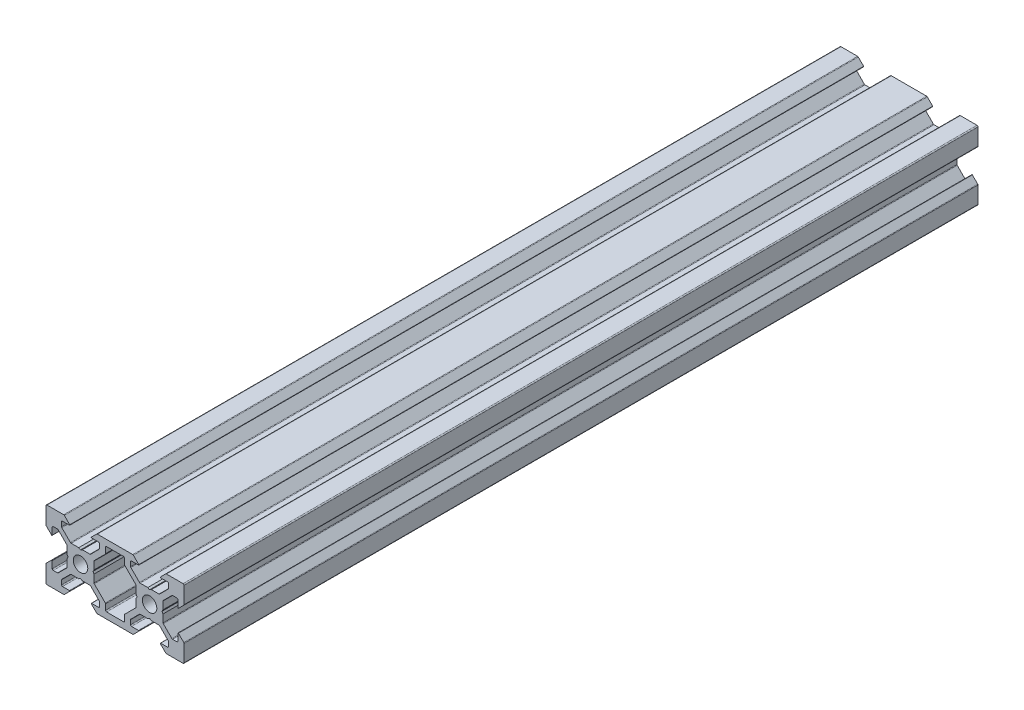
from build123d import *

# Parameters (mm, degrees)
BOSS_EXTRU_2_DEPTH = 230


with BuildPart() as part:
    # Esquisse1 → Boss.-Extru.2 (new body)
    with BuildSketch(Plane.XY):
        with BuildLine():
            Line((12.187742376, 2.734678815), (11.668127134, 3.034678815))
            Line((11.668127134, 3.034678815), (9.472006445, 3.034678815))
            ThreePointArc((9.472006445, 3.034678815), (9.357201415, 3.057514955), (9.25987441, 3.12254678))
            Line((9.25987441, 3.12254678), (6.776270514, 5.606150677))
            ThreePointArc((6.776270514, 5.606150677), (6.711238688, 5.703477682), (6.688402548, 5.818282711))
            Line((6.688402548, 5.818282711), (6.688402548, 7.034018643))
            ThreePointArc((6.688402548, 7.034018643), (6.776270514, 7.246150677), (6.988402548, 7.334018643))
            Line((6.988402548, 7.334018643), (8.987742376, 7.334018643))
            ThreePointArc((8.987742376, 7.334018643), (9.080130329, 7.3957503), (9.058453054, 7.504729321))
            Line((9.058453054, 7.504729321), (7.517031698, 9.046150677))
            ThreePointArc((7.517031698, 9.046150677), (7.419704693, 9.111182503), (7.304899664, 9.134018643))
            Line((7.304899664, 9.134018643), (2.187742376, 9.134018643))
            Line((2.187742376, 9.134018643), (-2.929414911, 9.134018643))
            ThreePointArc((-2.929414911, 9.134018643), (-3.044219941, 9.111182503), (-3.141546946, 9.046150677))
            Line((-3.141546946, 9.046150677), (-4.682968302, 7.504729321))
            ThreePointArc((-4.682968302, 7.504729321), (-4.704645577, 7.3957503), (-4.612257624, 7.334018643))
            Line((-4.612257624, 7.334018643), (-2.612917796, 7.334018643))
            ThreePointArc((-2.612917796, 7.334018643), (-2.400785761, 7.246150677), (-2.312917796, 7.034018643))
            Line((-2.312917796, 7.034018643), (-2.312917796, 5.818282711))
            ThreePointArc((-2.312917796, 5.818282711), (-2.335753936, 5.703477682), (-2.400785761, 5.606150677))
            Line((-2.400785761, 5.606150677), (-4.884389658, 3.12254678))
            ThreePointArc((-4.884389658, 3.12254678), (-4.981716663, 3.057514955), (-5.096521693, 3.034678815))
            Line((-5.096521693, 3.034678815), (-7.292642382, 3.034678815))
            Line((-7.292642382, 3.034678815), (-7.812257624, 2.734678815))
            Line((-7.812257624, 2.734678815), (-8.331872866, 3.034678815))
            Line((-8.331872866, 3.034678815), (-10.527993555, 3.034678815))
            ThreePointArc((-10.527993555, 3.034678815), (-10.642798585, 3.057514955), (-10.74012559, 3.12254678))
            Line((-10.74012559, 3.12254678), (-13.223729486, 5.606150677))
            ThreePointArc((-13.223729486, 5.606150677), (-13.288761312, 5.703477682), (-13.311597452, 5.818282711))
            Line((-13.311597452, 5.818282711), (-13.311597452, 7.034018643))
            ThreePointArc((-13.311597452, 7.034018643), (-13.223729486, 7.246150677), (-13.011597452, 7.334018643))
            Line((-13.011597452, 7.334018643), (-11.012257624, 7.334018643))
            ThreePointArc((-11.012257624, 7.334018643), (-10.919869671, 7.3957503), (-10.941546946, 7.504729321))
            Line((-10.941546946, 7.504729321), (-12.482968302, 9.046150677))
            ThreePointArc((-12.482968302, 9.046150677), (-12.580295307, 9.111182503), (-12.695100336, 9.134018643))
            Line((-12.695100336, 9.134018643), (-17.512257624, 9.134018643))
            ThreePointArc((-17.512257624, 9.134018643), (-17.724389658, 9.046150677), (-17.812257624, 8.834018643))
            Line((-17.812257624, 8.834018643), (-17.812257624, 4.016861355))
            ThreePointArc((-17.812257624, 4.016861355), (-17.789421484, 3.902056326), (-17.724389658, 3.804729321))
            Line((-17.724389658, 3.804729321), (-16.182968302, 2.263307965))
            ThreePointArc((-16.182968302, 2.263307965), (-16.073989281, 2.24163069), (-16.012257624, 2.334018643))
            Line((-16.012257624, 2.334018643), (-16.012257624, 4.333358471))
            ThreePointArc((-16.012257624, 4.333358471), (-15.924389658, 4.545490505), (-15.712257624, 4.633358471))
            Line((-15.712257624, 4.633358471), (-14.496521693, 4.633358471))
            ThreePointArc((-14.496521693, 4.633358471), (-14.381716663, 4.610522331), (-14.284389658, 4.545490505))
            Line((-14.284389658, 4.545490505), (-11.800785761, 2.061886608))
            ThreePointArc((-11.800785761, 2.061886608), (-11.735753936, 1.964559604), (-11.712917796, 1.849754574))
            Line((-11.712917796, 1.849754574), (-11.712917796, -0.346366115))
            Line((-11.712917796, -0.346366115), (-11.412917796, -0.865981357))
            Line((-11.412917796, -0.865981357), (-11.712917796, -1.385596599))
            Line((-11.712917796, -1.385596599), (-11.712917796, -3.581717289))
            ThreePointArc((-11.712917796, -3.581717289), (-11.735753936, -3.696522318), (-11.800785761, -3.793849323))
            Line((-11.800785761, -3.793849323), (-14.284389658, -6.27745322))
            ThreePointArc((-14.284389658, -6.27745322), (-14.381716663, -6.342485045), (-14.496521693, -6.365321185))
            Line((-14.496521693, -6.365321185), (-15.712257624, -6.365321185))
            ThreePointArc((-15.712257624, -6.365321185), (-15.924389658, -6.27745322), (-16.012257624, -6.065321185))
            Line((-16.012257624, -6.065321185), (-16.012257624, -4.065981357))
            ThreePointArc((-16.012257624, -4.065981357), (-16.073989281, -3.973593404), (-16.182968302, -3.995270679))
            Line((-16.182968302, -3.995270679), (-17.724389658, -5.536692035))
            ThreePointArc((-17.724389658, -5.536692035), (-17.789421484, -5.63401904), (-17.812257624, -5.74882407))
            Line((-17.812257624, -5.74882407), (-17.812257624, -10.565981357))
            ThreePointArc((-17.812257624, -10.565981357), (-17.724389658, -10.778113392), (-17.512257624, -10.865981357))
            Line((-17.512257624, -10.865981357), (-12.695100336, -10.865981357))
            ThreePointArc((-12.695100336, -10.865981357), (-12.580295307, -10.843145217), (-12.482968302, -10.778113392))
            Line((-12.482968302, -10.778113392), (-10.941546946, -9.236692035))
            ThreePointArc((-10.941546946, -9.236692035), (-10.919869671, -9.127713014), (-11.012257624, -9.065981357))
            Line((-11.012257624, -9.065981357), (-13.011597452, -9.065981357))
            ThreePointArc((-13.011597452, -9.065981357), (-13.223729486, -8.978113392), (-13.311597452, -8.765981357))
            Line((-13.311597452, -8.765981357), (-13.311597452, -7.550245426))
            ThreePointArc((-13.311597452, -7.550245426), (-13.288761312, -7.435440396), (-13.223729486, -7.338113392))
            Line((-13.223729486, -7.338113392), (-10.74012559, -4.854509495))
            ThreePointArc((-10.74012559, -4.854509495), (-10.642798585, -4.789477669), (-10.527993555, -4.766641529))
            Line((-10.527993555, -4.766641529), (-8.331872866, -4.766641529))
            Line((-8.331872866, -4.766641529), (-7.812257624, -4.466641529))
            Line((-7.812257624, -4.466641529), (-7.292642382, -4.766641529))
            Line((-7.292642382, -4.766641529), (-5.096521693, -4.766641529))
            ThreePointArc((-5.096521693, -4.766641529), (-4.981716663, -4.789477669), (-4.884389658, -4.854509495))
            Line((-4.884389658, -4.854509495), (-2.400785761, -7.338113392))
            ThreePointArc((-2.400785761, -7.338113392), (-2.335753936, -7.435440396), (-2.312917796, -7.550245426))
            Line((-2.312917796, -7.550245426), (-2.312917796, -8.765981357))
            ThreePointArc((-2.312917796, -8.765981357), (-2.400785761, -8.978113392), (-2.612917796, -9.065981357))
            Line((-2.612917796, -9.065981357), (-4.612257624, -9.065981357))
            ThreePointArc((-4.612257624, -9.065981357), (-4.704645577, -9.127713014), (-4.682968302, -9.236692035))
            Line((-4.682968302, -9.236692035), (-3.141546946, -10.778113392))
            ThreePointArc((-3.141546946, -10.778113392), (-3.044219941, -10.843145217), (-2.929414911, -10.865981357))
            Line((-2.929414911, -10.865981357), (2.187742376, -10.865981357))
            Line((2.187742376, -10.865981357), (7.304899664, -10.865981357))
            ThreePointArc((7.304899664, -10.865981357), (7.419704693, -10.843145217), (7.517031698, -10.778113392))
            Line((7.517031698, -10.778113392), (9.058453054, -9.236692035))
            ThreePointArc((9.058453054, -9.236692035), (9.080130329, -9.127713014), (8.987742376, -9.065981357))
            Line((8.987742376, -9.065981357), (6.988402548, -9.065981357))
            ThreePointArc((6.988402548, -9.065981357), (6.776270514, -8.978113392), (6.688402548, -8.765981357))
            Line((6.688402548, -8.765981357), (6.688402548, -7.550245426))
            ThreePointArc((6.688402548, -7.550245426), (6.711238688, -7.435440396), (6.776270514, -7.338113392))
            Line((6.776270514, -7.338113392), (9.25987441, -4.854509495))
            ThreePointArc((9.25987441, -4.854509495), (9.357201415, -4.789477669), (9.472006445, -4.766641529))
            Line((9.472006445, -4.766641529), (11.668127134, -4.766641529))
            Line((11.668127134, -4.766641529), (12.187742376, -4.466641529))
            Line((12.187742376, -4.466641529), (12.707357618, -4.766641529))
            Line((12.707357618, -4.766641529), (14.903478307, -4.766641529))
            ThreePointArc((14.903478307, -4.766641529), (15.018283337, -4.789477669), (15.115610342, -4.854509495))
            Line((15.115610342, -4.854509495), (17.599214239, -7.338113392))
            ThreePointArc((17.599214239, -7.338113392), (17.664246064, -7.435440396), (17.687082204, -7.550245426))
            Line((17.687082204, -7.550245426), (17.687082204, -8.765981357))
            ThreePointArc((17.687082204, -8.765981357), (17.599214239, -8.978113392), (17.387082204, -9.065981357))
            Line((17.387082204, -9.065981357), (15.387742376, -9.065981357))
            ThreePointArc((15.387742376, -9.065981357), (15.295354423, -9.127713014), (15.317031698, -9.236692035))
            Line((15.317031698, -9.236692035), (16.858453054, -10.778113392))
            ThreePointArc((16.858453054, -10.778113392), (16.955780059, -10.843145217), (17.070585089, -10.865981357))
            Line((17.070585089, -10.865981357), (21.887742376, -10.865981357))
            ThreePointArc((21.887742376, -10.865981357), (22.099874411, -10.778113392), (22.187742376, -10.565981357))
            Line((22.187742376, -10.565981357), (22.187742376, -5.74882407))
            ThreePointArc((22.187742376, -5.74882407), (22.164906236, -5.63401904), (22.09987441, -5.536692035))
            Line((22.09987441, -5.536692035), (20.558453054, -3.995270679))
            ThreePointArc((20.558453054, -3.995270679), (20.449474033, -3.973593404), (20.387742376, -4.065981357))
            Line((20.387742376, -4.065981357), (20.387742376, -6.065321185))
            ThreePointArc((20.387742376, -6.065321185), (20.29987441, -6.27745322), (20.087742376, -6.365321185))
            Line((20.087742376, -6.365321185), (18.872006445, -6.365321185))
            ThreePointArc((18.872006445, -6.365321185), (18.757201415, -6.342485045), (18.65987441, -6.27745322))
            Line((18.65987441, -6.27745322), (16.176270514, -3.793849323))
            ThreePointArc((16.176270514, -3.793849323), (16.111238688, -3.696522318), (16.088402548, -3.581717289))
            Line((16.088402548, -3.581717289), (16.088402548, -1.385596599))
            Line((16.088402548, -1.385596599), (15.788402548, -0.865981357))
            Line((15.788402548, -0.865981357), (16.088402548, -0.346366115))
            Line((16.088402548, -0.346366115), (16.088402548, 1.849754574))
            ThreePointArc((16.088402548, 1.849754574), (16.111238688, 1.964559604), (16.176270514, 2.061886608))
            Line((16.176270514, 2.061886608), (18.659874411, 4.545490505))
            ThreePointArc((18.659874411, 4.545490505), (18.757201415, 4.610522331), (18.872006445, 4.633358471))
            Line((18.872006445, 4.633358471), (20.087742376, 4.633358471))
            ThreePointArc((20.087742376, 4.633358471), (20.299874411, 4.545490505), (20.387742376, 4.333358471))
            Line((20.387742376, 4.333358471), (20.387742376, 2.334018643))
            ThreePointArc((20.387742376, 2.334018643), (20.449474033, 2.24163069), (20.558453054, 2.263307965))
            Line((20.558453054, 2.263307965), (22.099874411, 3.804729321))
            ThreePointArc((22.099874411, 3.804729321), (22.164906236, 3.902056326), (22.187742376, 4.016861355))
            Line((22.187742376, 4.016861355), (22.187742376, 8.834018643))
            ThreePointArc((22.187742376, 8.834018643), (22.099874411, 9.046150677), (21.887742376, 9.134018643))
            Line((21.887742376, 9.134018643), (17.070585089, 9.134018643))
            ThreePointArc((17.070585089, 9.134018643), (16.955780059, 9.111182503), (16.858453054, 9.046150677))
            Line((16.858453054, 9.046150677), (15.317031698, 7.504729321))
            ThreePointArc((15.317031698, 7.504729321), (15.295354423, 7.3957503), (15.387742376, 7.334018643))
            Line((15.387742376, 7.334018643), (17.387082204, 7.334018643))
            ThreePointArc((17.387082204, 7.334018643), (17.599214239, 7.246150677), (17.687082204, 7.034018643))
            Line((17.687082204, 7.034018643), (17.687082204, 5.818282711))
            ThreePointArc((17.687082204, 5.818282711), (17.664246064, 5.703477682), (17.599214239, 5.606150677))
            Line((17.599214239, 5.606150677), (15.115610342, 3.12254678))
            ThreePointArc((15.115610342, 3.12254678), (15.018283337, 3.057514955), (14.903478307, 3.034678815))
            Line((14.903478307, 3.034678815), (12.707357618, 3.034678815))
            Line((12.707357618, 3.034678815), (12.187742376, 2.734678815))
        make_face()
        with BuildLine():
            Line((4.927082204, -8.765981357), (4.927082204, -7.190245426))
            ThreePointArc((4.927082204, -7.190245426), (4.949918345, -7.075440396), (5.01495017, -6.978113392))
            Line((5.01495017, -6.978113392), (8.199214239, -3.793849323))
            ThreePointArc((8.199214239, -3.793849323), (8.264246064, -3.696522318), (8.287082204, -3.581717289))
            Line((8.287082204, -3.581717289), (8.287082204, -1.385596599))
            Line((8.287082204, -1.385596599), (8.587082204, -0.865981357))
            Line((8.587082204, -0.865981357), (8.287082204, -0.346366115))
            Line((8.287082204, -0.346366115), (8.287082204, 1.849754574))
            ThreePointArc((8.287082204, 1.849754574), (8.264246064, 1.964559604), (8.199214239, 2.061886608))
            Line((8.199214239, 2.061886608), (5.01495017, 5.246150677))
            ThreePointArc((5.01495017, 5.246150677), (4.949918345, 5.343477682), (4.927082204, 5.458282711))
            Line((4.927082204, 5.458282711), (4.927082204, 7.034018643))
            ThreePointArc((4.927082204, 7.034018643), (4.839214239, 7.246150677), (4.627082204, 7.334018643))
            Line((4.627082204, 7.334018643), (2.187742376, 7.334018643))
            Line((2.187742376, 7.334018643), (-0.251597452, 7.334018643))
            ThreePointArc((-0.251597452, 7.334018643), (-0.463729486, 7.246150677), (-0.551597452, 7.034018643))
            Line((-0.551597452, 7.034018643), (-0.551597452, 5.458282711))
            ThreePointArc((-0.551597452, 5.458282711), (-0.574433592, 5.343477682), (-0.639465418, 5.246150677))
            Line((-0.639465418, 5.246150677), (-3.823729486, 2.061886608))
            ThreePointArc((-3.823729486, 2.061886608), (-3.888761312, 1.964559604), (-3.911597452, 1.849754574))
            Line((-3.911597452, 1.849754574), (-3.911597452, -0.346366115))
            Line((-3.911597452, -0.346366115), (-4.211597452, -0.865981357))
            Line((-4.211597452, -0.865981357), (-3.911597452, -1.385596599))
            Line((-3.911597452, -1.385596599), (-3.911597452, -3.581717289))
            ThreePointArc((-3.911597452, -3.581717289), (-3.888761312, -3.696522318), (-3.823729486, -3.793849323))
            Line((-3.823729486, -3.793849323), (-0.639465418, -6.978113392))
            ThreePointArc((-0.639465418, -6.978113392), (-0.574433592, -7.075440396), (-0.551597452, -7.190245426))
            Line((-0.551597452, -7.190245426), (-0.551597452, -8.765981357))
            ThreePointArc((-0.551597452, -8.765981357), (-0.463729486, -8.978113392), (-0.251597452, -9.065981357))
            Line((-0.251597452, -9.065981357), (2.187742376, -9.065981357))
            Line((2.187742376, -9.065981357), (4.627082204, -9.065981357))
            ThreePointArc((4.627082204, -9.065981357), (4.839214239, -8.978113392), (4.927082204, -8.765981357))
        make_face(mode=Mode.SUBTRACT)
        with BuildLine():
            ThreePointArc((-7.812257624, 1.234018643), (-9.297181864, 0.618942883), (-9.912257624, -0.865981357))
            ThreePointArc((-9.912257624, -0.865981357), (-9.297181864, -2.350905598), (-7.812257624, -2.965981357))
            ThreePointArc((-7.812257624, -2.965981357), (-6.327333383, -2.350905598), (-5.712257624, -0.865981357))
            ThreePointArc((-5.712257624, -0.865981357), (-6.327333383, 0.618942883), (-7.812257624, 1.234018643))
        make_face(mode=Mode.SUBTRACT)
        with BuildLine():
            ThreePointArc((12.187742376, 1.234018643), (10.702818136, 0.618942883), (10.087742376, -0.865981357))
            ThreePointArc((10.087742376, -0.865981357), (10.702818136, -2.350905598), (12.187742376, -2.965981357))
            ThreePointArc((12.187742376, -2.965981357), (13.672666617, -2.350905598), (14.287742376, -0.865981357))
            ThreePointArc((14.287742376, -0.865981357), (13.672666617, 0.618942883), (12.187742376, 1.234018643))
        make_face(mode=Mode.SUBTRACT)
    extrude(amount=BOSS_EXTRU_2_DEPTH)


solid = part.part
